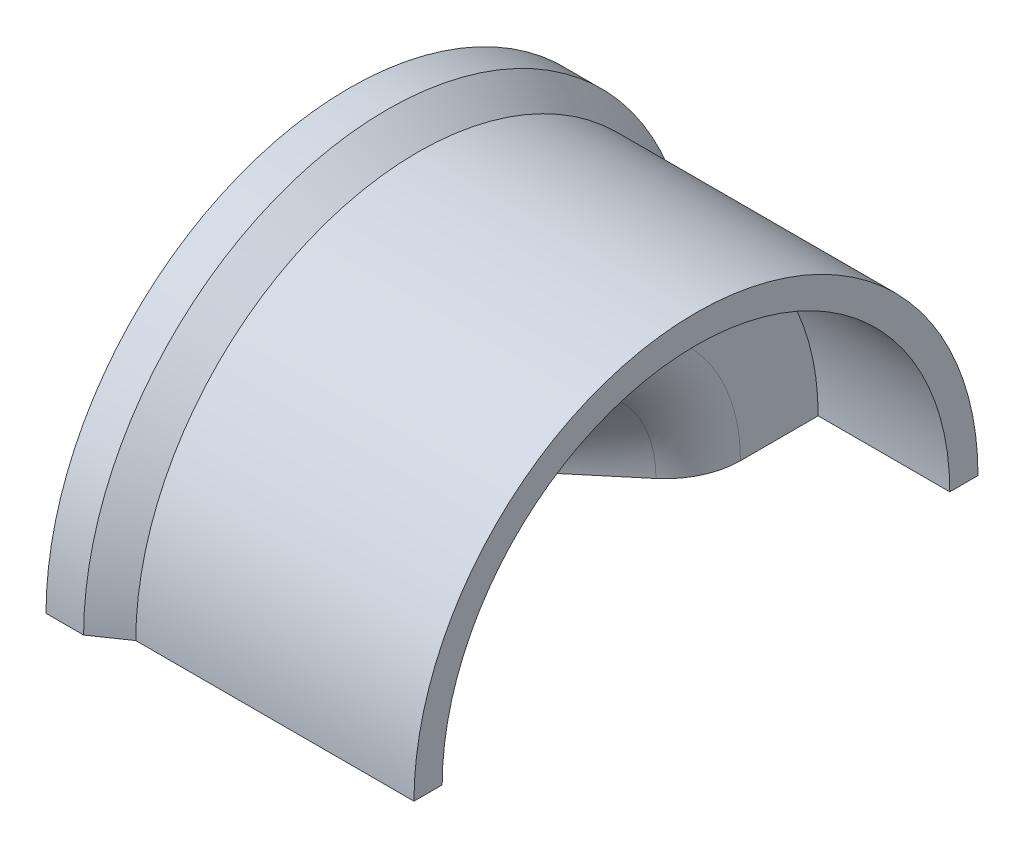
from build123d import *

# Parameters (mm, degrees)
SKETCH5_R               = 19.05
BOSS_EXTRUDE1_DEPTH     = 11.43
BOSS_EXTRUDE4_REACH     = 13.989
SKETCH12_R              = 19.05
SKETCH12_R_2            = 13.981282801
SKETCH11_R              = 17.145
CUT_EXTRUDE5_DEPTH      = 8.89
SKETCH13_R              = 9.525
CUT_EXTRUDE7_DEPTH      = 6.35
CUT_EXTRUDE7_TAPER      = 40
SKETCH14_W              = 44.104776143
SKETCH14_H              = 21.741572172
CUT_EXTRUDE8_DEPTH      = 1
CUT_EXTRUDE8_DEPTH_BACK = 24.418912122
FILLET6_R               = 5.08


with BuildPart() as part:
    # Sketch1 → Revolve4 (revolve)
    with BuildSketch(Plane(origin=(0, 0, 0), x_dir=(1, 0, 0), z_dir=(0, 1, 0))):
        with BuildLine():
            Line((22.460516589, 20.486669906), (19.920516589, 20.486669906))
            ThreePointArc((19.920516589, 20.486669906), (26.322608025, 11.119844052), (28.575, 0))
            Line((28.575, 0), (31.909428711, 0))
            Line((31.909428711, 0), (31.909428711, 13.981282801))
            Line((31.909428711, 13.981282801), (22.460516589, 20.486669906))
        make_face()
    revolve(axis=Axis((28.575, 0, 0), (1, 0, 0)))

    # Sketch5 → Boss-Extrude1 (add)
    with BuildSketch(Plane(origin=(31.909428711, 0, 0), x_dir=(0, 0, -1), z_dir=(1, 0, 0))):
        Circle(SKETCH5_R)
    extrude(amount=BOSS_EXTRUDE1_DEPTH)

    # Sketch12 → Boss-Extrude4 (add, up to next)
    with BuildSketch(Plane.ZY.offset(-31.909428711), mode=Mode.PRIVATE) as boss_extrude4_sk1:
        Circle(SKETCH12_R)
        Circle(SKETCH12_R_2, mode=Mode.SUBTRACT)
    boss_extrude4_tool1 = extrude(boss_extrude4_sk1.sketch, amount=BOSS_EXTRUDE4_REACH, mode=Mode.PRIVATE) - part.part
    add(boss_extrude4_tool1.solids().sort_by_distance((31.909429, 0, -18.511185))[0])

    # Sketch11 → Cut-Extrude5 (cut)
    with BuildSketch(Plane(origin=(43.339428711, 0, 0), x_dir=(0, 0, -1), z_dir=(1, 0, 0))):
        Circle(SKETCH11_R)
    extrude(amount=-CUT_EXTRUDE5_DEPTH, mode=Mode.SUBTRACT)

    # Sketch13 → Cut-Extrude7 (cut)
    with BuildSketch(Plane(origin=(34.449428711, 0, 0), x_dir=(0, 0, -1), z_dir=(1, 0, 0))):
        Circle(SKETCH13_R)
    extrude(amount=-CUT_EXTRUDE7_DEPTH, taper=CUT_EXTRUDE7_TAPER, mode=Mode.SUBTRACT)

    # Sketch14 → Cut-Extrude8 (cut, two sides)
    with BuildSketch(Plane(origin=(43.339428711, 0, 0), x_dir=(0, 0, -1), z_dir=(1, 0, 0))) as cut_extrude8_sk:
        with Locations((0.388519875, -10.870786086)):
            Rectangle(SKETCH14_W, SKETCH14_H)
    extrude(amount=CUT_EXTRUDE8_DEPTH, mode=Mode.SUBTRACT)
    extrude(cut_extrude8_sk.sketch, amount=-CUT_EXTRUDE8_DEPTH_BACK, mode=Mode.SUBTRACT)

    # Fillet6
    fillet6_edges = [part.edges().sort_by_distance(p)[0] for p in [
        (34.449428711, 9.525, 0),
    ]]
    fillet(fillet6_edges, radius=FILLET6_R)


solid = part.part
